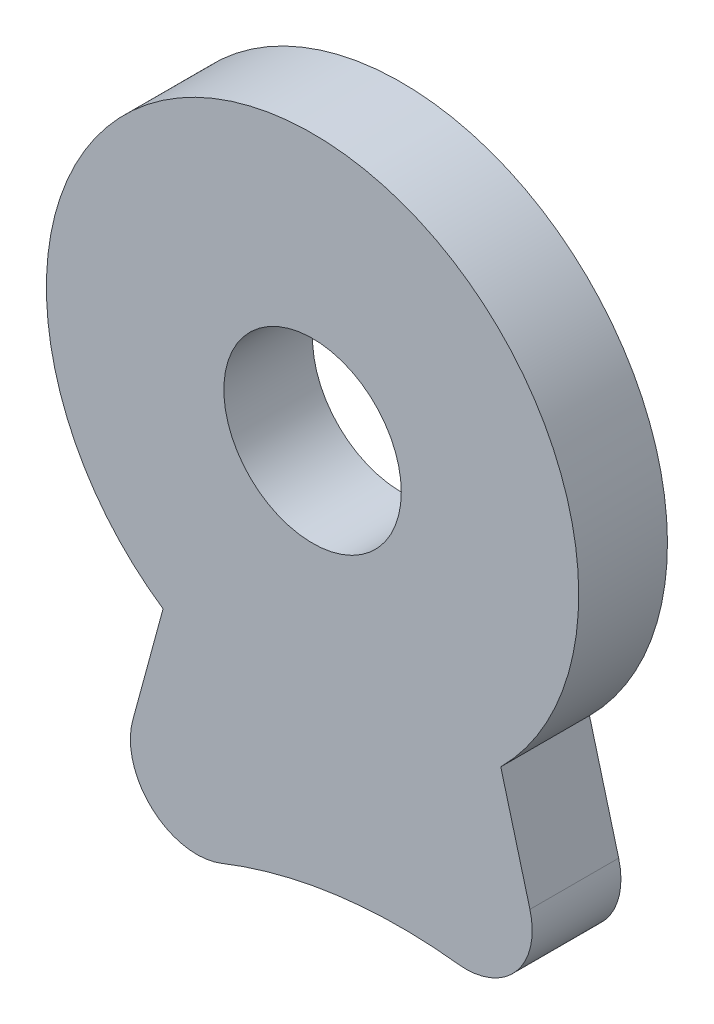
from build123d import *

# Parameters (mm, degrees)
SKETCH1_R           = 6
SKETCH1_R_2         = 2
BOSS_EXTRUDE1_DEPTH = 2
FILLET1_R           = 1.5


with BuildPart() as part:
    # Sketch1 → Boss-Extrude1 (new body)
    with BuildSketch(Plane.XY):
        with Locations((-174.416251328, -25.172160385)):
            Circle(SKETCH1_R)
        with Locations((-174.416251328, -25.172160385)):
            Circle(SKETCH1_R_2, mode=Mode.SUBTRACT)
        with BuildLine():
            ThreePointArc((-170.173610641, -29.414801072), (-173.850108495, -31.145390859), (-177.78627055, -30.13632904))
            Line((-177.78627055, -30.13632904), (-179.432101814, -36.199979912))
            ThreePointArc((-179.432101814, -36.199979912), (-174.407079396, -33.853814689), (-168.876035514, -34.257417374))
            Line((-168.876035514, -34.257417374), (-170.173610641, -29.414801072))
        make_face()
    extrude(amount=BOSS_EXTRUDE1_DEPTH)

    # Fillet1
    fillet1_edges = [part.edges().sort_by_distance(p)[0] for p in [
        (-168.876035514, -34.257417374, 1),
        (-179.432101814, -36.199979912, 1),
    ]]
    fillet(fillet1_edges, radius=FILLET1_R)


solid = part.part
